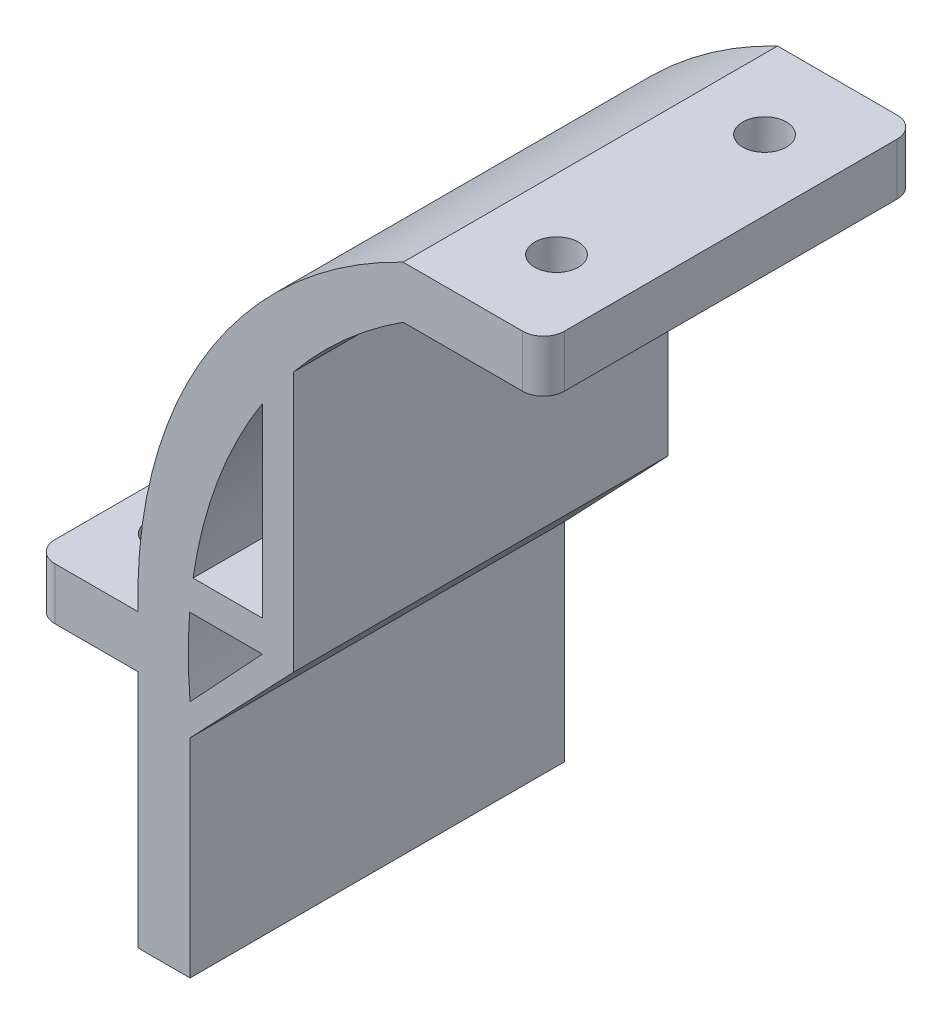
from build123d import *

# Parameters (mm, degrees)
SKETCH3_W           = 13.5
SKETCH3_H           = 5
SKETCH3_W_2         = 10
SKETCH3_W_3         = 5
SKETCH3_H_2         = 23
BOSS_EXTRUDE1_DEPTH = 45
FILLET1_R           = 2
SKETCH5_R           = 2.1
CUT_EXTRUDE2_DEPTH  = 45
SKETCH6_R           = 2.1
CUT_EXTRUDE3_DEPTH  = 45
SKETCH7_W           = 8.210459319
SKETCH7_H           = 32.58724939
BOSS_EXTRUDE2_DEPTH = 5
SKETCH8_R           = 2.1
CUT_EXTRUDE5_DEPTH  = 45
BOSS_EXTRUDE3_DEPTH = 45
SKETCH10_W          = 60.355694637
SKETCH10_H          = 75.381613981
CUT_EXTRUDE7_DEPTH  = 9
SKETCH13_W          = 6.095088126
SKETCH13_H          = 29.055723933
BOSS_EXTRUDE6_DEPTH = 5
SKETCH14_W          = 6.424633762
SKETCH14_H          = 30.784703445
BOSS_EXTRUDE7_DEPTH = 5
FILLET3_R           = 2
SKETCH15_R          = 2.1
CUT_EXTRUDE8_DEPTH  = 9
SKETCH16_R          = 2.1
CUT_EXTRUDE9_DEPTH  = 9


with BuildPart() as part:
    # Sketch3 → Boss-Extrude1 (new body)
    with BuildSketch(Plane.XY):
        with BuildLine():
            ThreePointArc((-5.06519953, 257.264696919), (-21.146881422, 239.197551787), (-25.551614771, 215.414352888))
            Line((-25.551614771, 215.414352888), (-30.551614771, 215.414352888))
            Line((-30.551614771, 215.414352888), (-30.551614771, 220.414352888))
            ThreePointArc((-30.551614771, 220.414352888), (-24.004098535, 245.112635185), (-5.06519953, 262.264696919))
            Line((-5.06519953, 262.264696919), (-5.06519953, 257.264696919))
        make_face()
        with Locations((1.68480047, 259.764696919)):
            Rectangle(SKETCH3_W, SKETCH3_H)
        with Locations((-35.551614771, 217.914352888)):
            Rectangle(SKETCH3_W_2, SKETCH3_H)
        with Locations((-28.051614771, 203.914352888)):
            Rectangle(SKETCH3_W_3, SKETCH3_H_2)
    extrude(amount=BOSS_EXTRUDE1_DEPTH)

    # Fillet1
    fillet1_edges = [part.edges().sort_by_distance(p)[0] for p in [
        (-40.551614771, 217.914352888, 0),
        (8.43480047, 259.764696919, 45),
        (8.43480047, 259.764696919, 0),
        (-40.551614771, 217.914352888, 45),
    ]]
    fillet(fillet1_edges, radius=FILLET1_R)

    # Sketch5 → Cut-Extrude2 (cut)
    with BuildSketch(Plane(origin=(0, 262.264696919, 0), x_dir=(1, 0, 0), z_dir=(0, 1, 0))):
        with Locations((0.24480047, -40)):
            Circle(SKETCH5_R)
        with Locations((0.24480047, -14.8)):
            Circle(SKETCH5_R)
    extrude(amount=-CUT_EXTRUDE2_DEPTH, mode=Mode.SUBTRACT)

    # Sketch6 → Cut-Extrude3 (cut)
    with BuildSketch(Plane(origin=(0, 220.414352888, 0), x_dir=(1, 0, 0), z_dir=(0, 1, 0))):
        with Locations((-35.551614771, -10)):
            Circle(SKETCH6_R)
        with Locations((-35.551614771, -35)):
            Circle(SKETCH6_R)
    extrude(amount=-CUT_EXTRUDE3_DEPTH, mode=Mode.SUBTRACT)

    # Sketch7 → Boss-Extrude2 (add)
    with BuildSketch(Plane(origin=(0, 262.264696919, 0), x_dir=(1, 0, 0), z_dir=(0, 1, 0))):
        with Locations((1.09445166, -26.923464517)):
            Rectangle(SKETCH7_W, SKETCH7_H)
    extrude(amount=-BOSS_EXTRUDE2_DEPTH)

    # Sketch8 → Cut-Extrude5 (cut)
    with BuildSketch(Plane(origin=(0, 262.264696919, 0), x_dir=(1, 0, 0), z_dir=(0, 1, 0))):
        with Locations((0.24480047, -5)):
            Circle(SKETCH8_R)
        with Locations((0.24480047, -30.2)):
            Circle(SKETCH8_R)
    extrude(amount=-CUT_EXTRUDE5_DEPTH, mode=Mode.SUBTRACT)

    # Sketch9 → Boss-Extrude3 (add, through all)
    with BuildSketch(Plane.XY.offset(45)):
        with BuildLine():
            ThreePointArc((-25.265361734, 225.859750777), (-25.456525287, 224.362535182), (-25.597369426, 222.859750777))
            Line((-25.597369426, 222.859750777), (-18.597369426, 222.859750777))
            Line((-18.597369426, 222.859750777), (-15.597369426, 222.859750777))
            Line((-15.597369426, 222.859750777), (-15.597369426, 247.859750777))
            ThreePointArc((-15.597369426, 247.859750777), (-17.156118075, 245.834377519), (-18.597369426, 243.72377838))
            Line((-18.597369426, 243.72377838), (-18.597369426, 225.859750777))
            Line((-18.597369426, 225.859750777), (-25.265361734, 225.859750777))
        make_face()
        Polygon((-15.597369426, 222.859750777), (-18.597369426, 222.859750777), (-25.551614771, 215.414352888), (-25.551614771, 212.414352888), align=None)
    extrude(amount=-BOSS_EXTRUDE3_DEPTH)

    # Sketch10 → Cut-Extrude7 (cut)
    with BuildSketch(Plane.XY.offset(45)):
        with Locations((-21.743046849, 224.573889929)):
            Rectangle(SKETCH10_W, SKETCH10_H)
    extrude(amount=-CUT_EXTRUDE7_DEPTH, mode=Mode.SUBTRACT)

    # Sketch13 → Boss-Extrude6 (add)
    with BuildSketch(Plane(origin=(0, 220.414352888, 0), x_dir=(1, 0, 0), z_dir=(0, 1, 0))):
        with Locations((-35.175849568, -21.472138034)):
            Rectangle(SKETCH13_W, SKETCH13_H)
    extrude(amount=-BOSS_EXTRUDE6_DEPTH)

    # Sketch14 → Boss-Extrude7 (add)
    with BuildSketch(Plane(origin=(0, 262.264696919, 0), x_dir=(1, 0, 0), z_dir=(0, 1, 0))):
        with Locations((0.1637931, -17.411075239)):
            Rectangle(SKETCH14_W, SKETCH14_H)
    extrude(amount=-BOSS_EXTRUDE7_DEPTH)

    # Fillet3
    fillet3_edges = [part.edges().sort_by_distance(p)[0] for p in [
        (-40.551614771, 217.914352888, 36),
        (8.43480047, 259.764696919, 36),
    ]]
    fillet(fillet3_edges, radius=FILLET3_R)

    # Sketch15 → Cut-Extrude8 (cut)
    with BuildSketch(Plane(origin=(0, 220.414352888, 0), x_dir=(1, 0, 0), z_dir=(0, 1, 0))):
        with Locations((-35.551614771, -8)):
            Circle(SKETCH15_R)
        with Locations((-35.551614771, -28)):
            Circle(SKETCH15_R)
    extrude(amount=-CUT_EXTRUDE8_DEPTH, mode=Mode.SUBTRACT)

    # Sketch16 → Cut-Extrude9 (cut)
    with BuildSketch(Plane(origin=(0, 262.264696919, 0), x_dir=(1, 0, 0), z_dir=(0, 1, 0))):
        with Locations((1.68480047, -8)):
            Circle(SKETCH16_R)
        with Locations((1.68480047, -28)):
            Circle(SKETCH16_R)
    extrude(amount=-CUT_EXTRUDE9_DEPTH, mode=Mode.SUBTRACT)


solid = part.part
